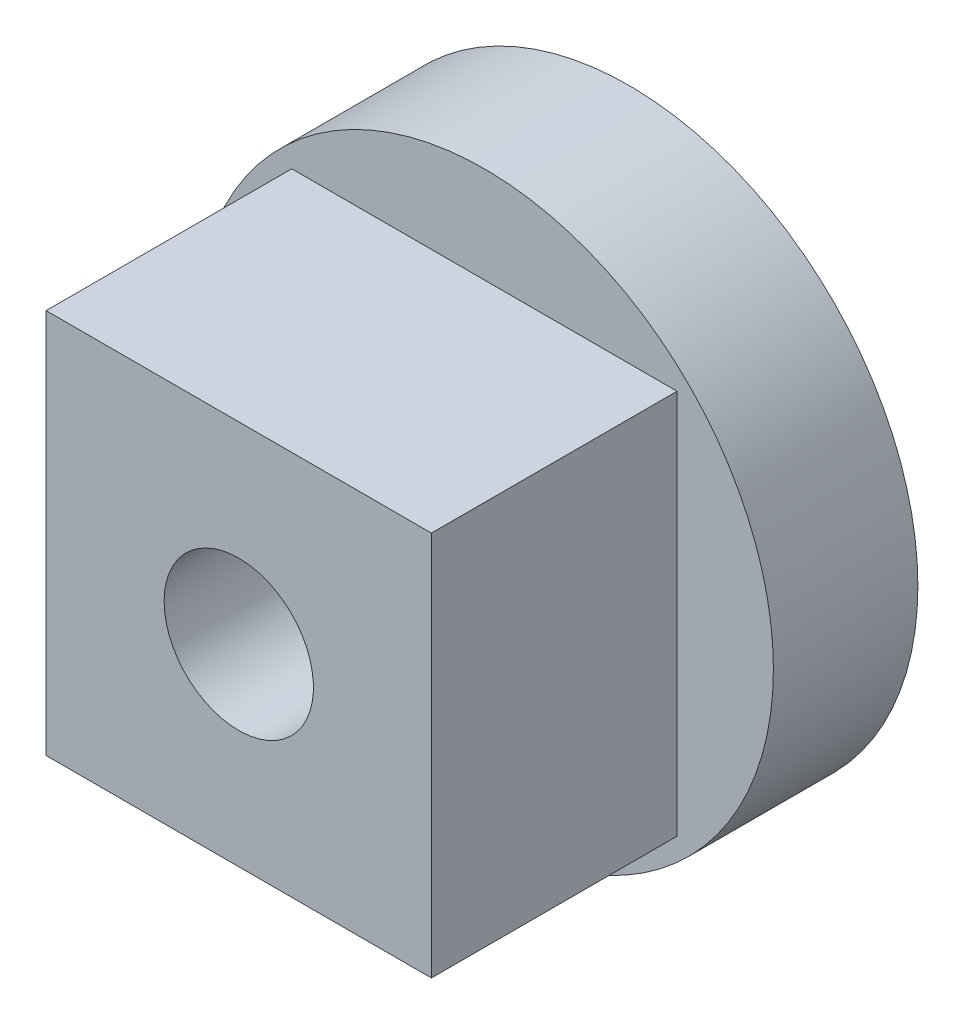
from build123d import *

# Parameters (mm, degrees)
SKETCH_1_R          = 6
EXTRUDE_1_DEPTH     = 3
SKETCH_2_W          = 8
SKETCH_2_H          = 8
EXTRUDE_2_DEPTH     = 5.1
SKETCH_4_R          = 2.85
CUT_EXTRUDE_1_DEPTH = 1
SKETCH_5_R          = 1.55
CUT_EXTRUDE_2_DEPTH = 8.1


with BuildPart() as part:
    # 草图1 → 凸台-拉伸1 (new body)
    with BuildSketch(Plane.XY):
        Circle(SKETCH_1_R)
    extrude(amount=EXTRUDE_1_DEPTH)

    # 草图2 → 凸台-拉伸2 (add)
    with BuildSketch(Plane.XY.offset(3)):
        Rectangle(SKETCH_2_W, SKETCH_2_H)
    extrude(amount=EXTRUDE_2_DEPTH)

    # 草图4 → 切除-拉伸1 (cut)
    with BuildSketch(Plane(origin=(0, 0, 0), x_dir=(-1, 0, 0), z_dir=(0, 0, -1))):
        Circle(SKETCH_4_R)
    extrude(amount=-CUT_EXTRUDE_1_DEPTH, mode=Mode.SUBTRACT)

    # 草图5 → 切除-拉伸2 (cut, through all)
    with BuildSketch(Plane(origin=(0, 0, 1), x_dir=(-1, 0, 0), z_dir=(0, 0, -1))):
        Circle(SKETCH_5_R)
    extrude(amount=-CUT_EXTRUDE_2_DEPTH, mode=Mode.SUBTRACT)


solid = part.part
